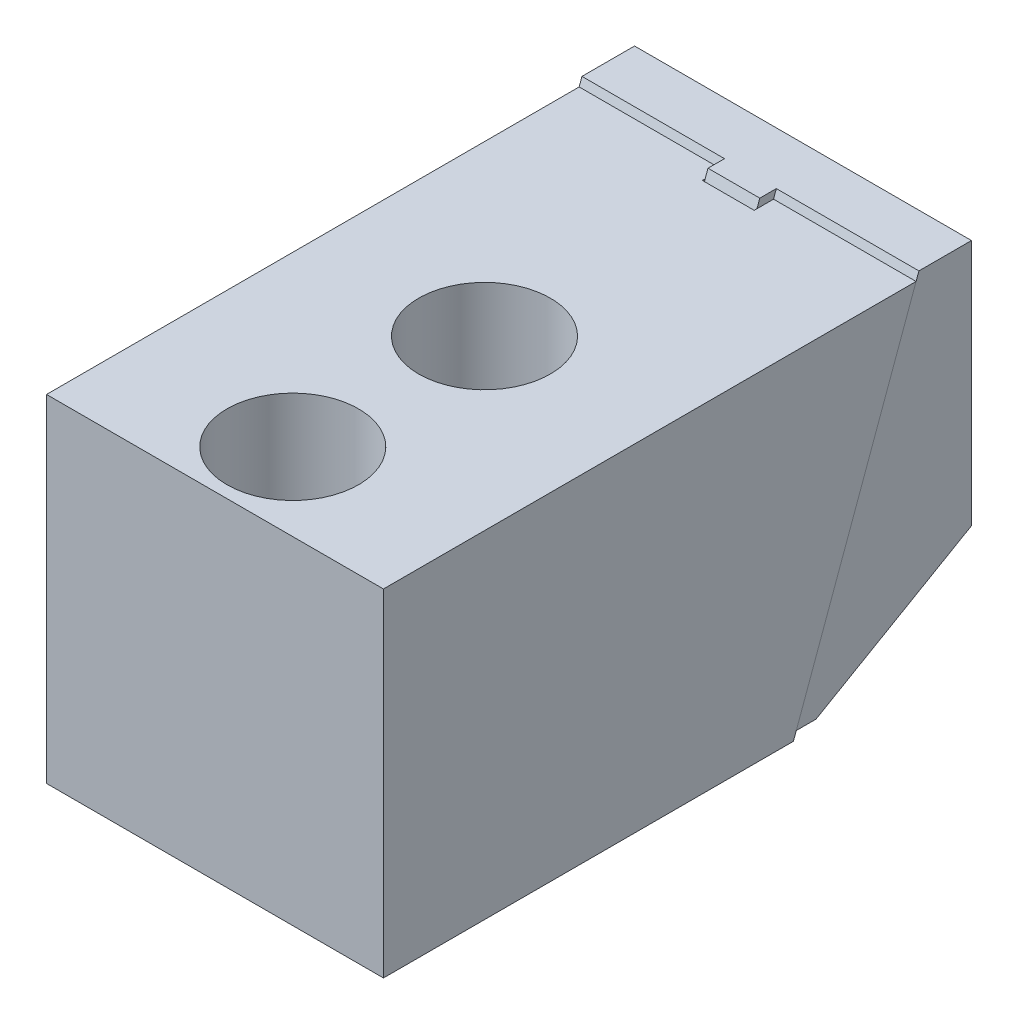
from build123d import *

# Parameters (mm, degrees)
EXTRUDE1_DEPTH     = 32.512
CUT_EXTRUDE1_DEPTH = 5.0038
HOLE1_D            = 16.51
HOLE1_DEPTH        = 65.024
HOLE1_CBORE_D      = 25.4
HOLE1_CBORE_DEPTH  = 18.034
EXTRUDE2_DEPTH     = 32.512
EXTRUDE3_DEPTH     = 4.99999
SKETCH10_R         = 5
EXTRUDE4_DEPTH     = 6
CUT_EXTRUDE2_DEPTH = 6
SKETCH12_R         = 16.002
CUT_EXTRUDE3_DEPTH = 5.842


with BuildPart() as part:
    # Sketch1 → Extrude1 (new body, symmetric)
    with BuildSketch(Plane(origin=(0, 0, 0), x_dir=(0, 0, -1), z_dir=(1, 0, 0))):
        Polygon((0, 65.024), (0, 0), (79.126999487, 0), (102.7938, 65.024), align=None)
    extrude(amount=EXTRUDE1_DEPTH, both=True)

    # Sketch2 → Cut-Extrude1 (cut, symmetric)
    with BuildSketch(Plane(origin=(0, 0, 0), x_dir=(0, 0, -1), z_dir=(1, 0, 0))):
        Polygon((99.06, 65.024), (75.393199487, 0), (79.126999487, 0), (102.7938, 65.024), align=None)
    extrude(amount=CUT_EXTRUDE1_DEPTH, both=True, mode=Mode.SUBTRACT)

    # Hole1
    with Locations(Plane(origin=(0, 65.024, 0), x_dir=(-1, 0, 0), z_dir=(0, 1, 0))):
        with Locations((0, -15.0114), (0, -52.0192)):
            CounterBoreHole(HOLE1_D / 2, HOLE1_CBORE_D / 2, HOLE1_CBORE_DEPTH, depth=HOLE1_DEPTH)

    # Sketch12 → Cut-Extrude3 (cut)
    with BuildSketch(Plane.XZ):
        with Locations(Location((0, -52.0192, 0), (0, 0, 270))):  # turned: the seam where the file's is
            Circle(SKETCH12_R)
    extrude(amount=-CUT_EXTRUDE3_DEPTH, mode=Mode.SUBTRACT)


with BuildPart() as body_2:
    # Sketch7 → Extrude2 (new body, symmetric)
    with BuildSketch(Plane(origin=(0, 0, 0), x_dir=(0, 0, -1), z_dir=(1, 0, 0))):
        Polygon((79.680312331, 1.520214545), (83.483230271, 1.520214545), (113.4872, 18.843014545), (113.4872, 66.518814545), (103.337868, 66.518814545), align=None)
    extrude(amount=EXTRUDE2_DEPTH, both=True)

    # Sketch8 → Extrude3 (add, symmetric)
    with BuildSketch(Plane(origin=(0, 0, 0), x_dir=(0, 0, -1), z_dir=(1, 0, 0))):
        Polygon((103.337868, 66.518814545), (100.145334683, 66.518814545), (76.487779014, 1.520214545), (79.680312331, 1.520214545), align=None)
    extrude(amount=EXTRUDE3_DEPTH, both=True)

    # Sketch9 → Cut-Revolve1 (revolve, cut)
    with BuildSketch(Plane(origin=(0, 0, 0), x_dir=(0, 0, -1), z_dir=(1, 0, 0)), mode=Mode.PRIVATE) as cut_revolve1_sk:
        Polygon((76.1873, 31.020214545), (113.4872, 31.020214545), (113.4872, 36.520330545), (106.18724, 36.520330545), (106.18724, 34.120284545), (101.5873, 34.120284545), (101.5873, 44.020214545), (76.1873, 44.020214545), align=None)
    revolve(cut_revolve1_sk.sketch.rotate(Axis((0, 31.020214545, -47.431210166), (0, 0, -1)), 90), axis=Axis((0, 31.020214545, -47.431210166), (0, 0, -1)), mode=Mode.SUBTRACT)  # turned: the seam where the file's is

    # Sketch10 → Extrude4 (add)
    with BuildSketch(Plane(origin=(0, 0, -106.18724), x_dir=(-1, 0, 0), z_dir=(0, 0, -1))):
        with Locations((0, 31.020214545)):
            Circle(SKETCH10_R)
    extrude(amount=EXTRUDE4_DEPTH)

    # Sketch11 → Cut-Extrude2 (cut)
    with BuildSketch(Plane(origin=(0, 0, -112.18724), x_dir=(-1, 0, 0), z_dir=(0, 0, -1))):
        Polygon((1.732050808, 28.020214545), (3.464101615, 31.020214545), (1.732050808, 34.020214545), (-1.732050808, 34.020214545), (-3.464101615, 31.020214545), (-1.732050808, 28.020214545), align=None)
    extrude(amount=-CUT_EXTRUDE2_DEPTH, mode=Mode.SUBTRACT)


solid = Compound([part.part, body_2.part])
